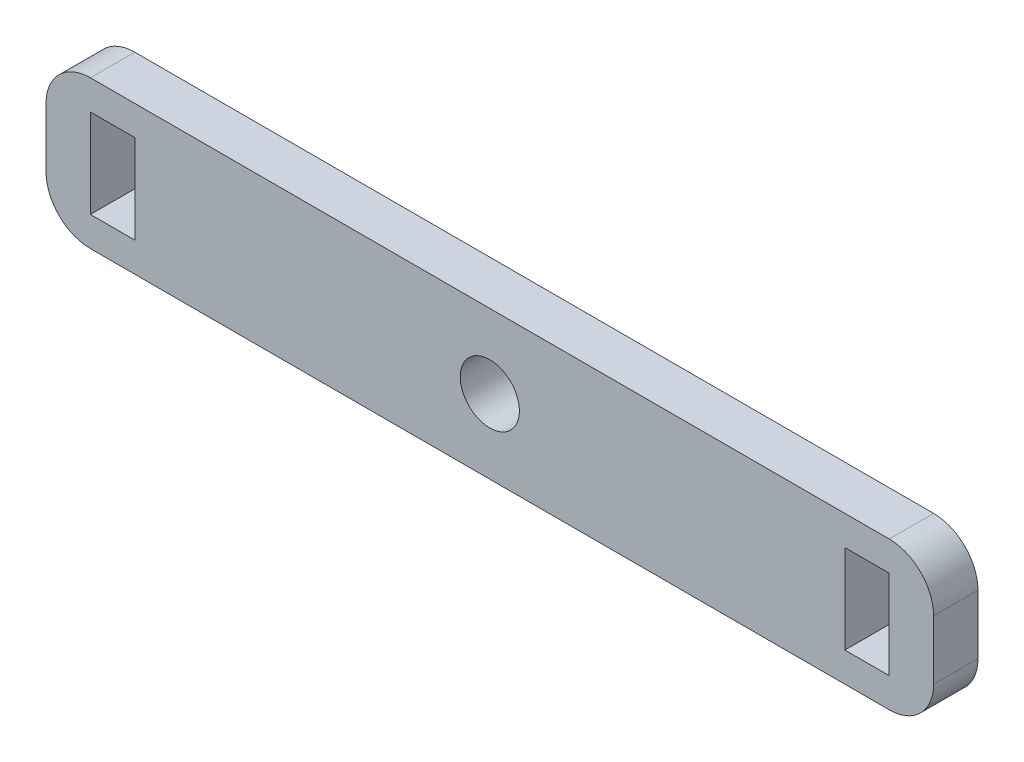
from build123d import *

# Parameters (mm, degrees)
SKETCH1_W           = 60
SKETCH1_H           = 10
BOSS_EXTRUDE1_DEPTH = 3
SKETCH2_R           = 2
CUT_EXTRUDE1_DEPTH  = 3
SKETCH3_W           = 3
SKETCH3_H           = 6
CUT_EXTRUDE2_DEPTH  = 3
FILLET1_R           = 3


with BuildPart() as part:
    # Sketch1 → Boss-Extrude1 (new body)
    with BuildSketch(Plane.XY):
        Rectangle(SKETCH1_W, SKETCH1_H)
    extrude(amount=BOSS_EXTRUDE1_DEPTH)

    # Sketch2 → Cut-Extrude1 (cut)
    with BuildSketch(Plane.XY.offset(3)):
        Circle(SKETCH2_R)
    extrude(amount=-CUT_EXTRUDE1_DEPTH, mode=Mode.SUBTRACT)

    # Sketch3 → Cut-Extrude2 (cut)
    with BuildSketch(Plane.XY.offset(3)):
        with Locations((-25.5, 0)):
            Rectangle(SKETCH3_W, SKETCH3_H)
    cut_extrude2 = extrude(amount=-CUT_EXTRUDE2_DEPTH, mode=Mode.SUBTRACT)

    # Mirror1: Cut-Extrude2 across plane
    add(cut_extrude2.mirror(Plane(origin=(0, 0, 0), x_dir=(0, 0, 1), z_dir=(1, 0, 0))), mode=Mode.SUBTRACT)

    # Fillet1
    fillet1_edges = [part.edges().sort_by_distance(p)[0] for p in [
        (30, -5, 1.5),
        (-30, -5, 1.5),
        (-30, 5, 1.5),
        (30, 5, 1.5),
    ]]
    fillet(fillet1_edges, radius=FILLET1_R)


solid = part.part
